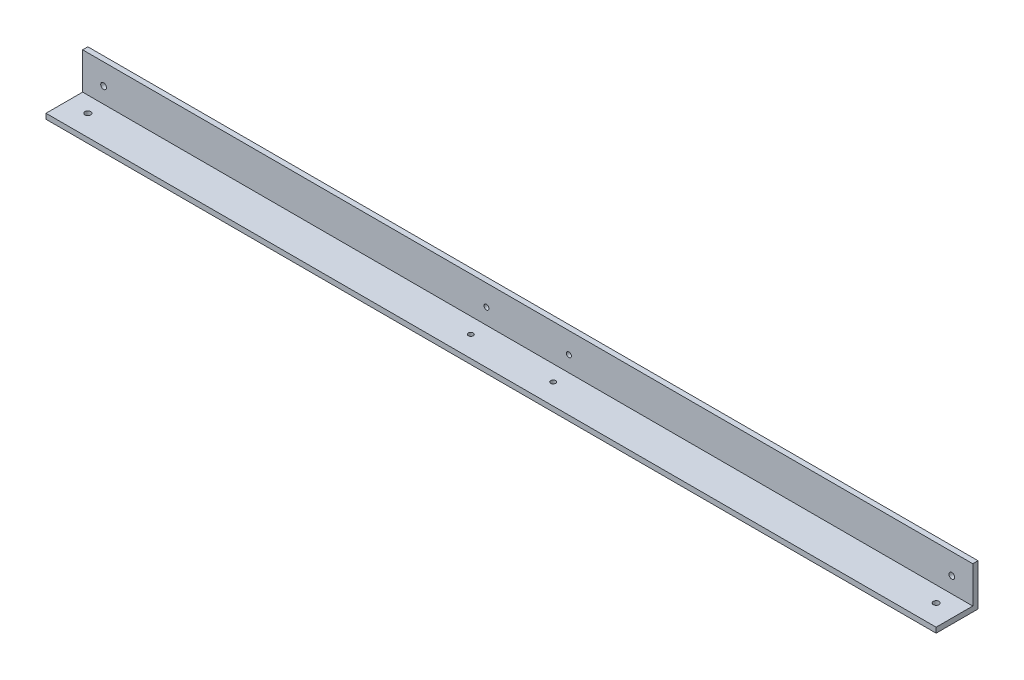
from build123d import *

# Parameters (mm, degrees)
SALIENTE_EXTRUIR1_DEPTH      = 270
SALIENTE_EXTRUIR1_DEPTH_BACK = 270
CROQUIS3_R                   = 1.5
CROQUIS3_R_2                 = 1.75
CORTAR_EXTRUIR1_DEPTH        = 3.175
CROQUIS4_R                   = 1.5
CROQUIS4_R_2                 = 1.75
CORTAR_EXTRUIR2_DEPTH        = 3.175


with BuildPart() as part:
    # Croquis1 → Saliente-Extruir1 (new body, two sides)
    with BuildSketch(Plane(origin=(0, 0, 0), x_dir=(0, 0, -1), z_dir=(1, 0, 0))) as saliente_extruir1_sk:
        Polygon((0, 25.4), (0, 0), (-25.4, 0), (-25.4, 3.175), (-3.175, 3.175), (-3.175, 25.4), align=None)
    extrude(amount=SALIENTE_EXTRUIR1_DEPTH)
    extrude(saliente_extruir1_sk.sketch, amount=-SALIENTE_EXTRUIR1_DEPTH_BACK)

    # Croquis3 → Cortar-Extruir1 (cut)
    with BuildSketch(Plane(origin=(0, 0, 0), x_dir=(-1, 0, 0), z_dir=(0, -1, 0))):
        with Locations((-25, -12.7)):
            Circle(CROQUIS3_R)
        with Locations((25, -12.7)):
            Circle(CROQUIS3_R)
        with Locations((-257.3, -12.7)):
            Circle(CROQUIS3_R_2)
        with Locations((257.3, -12.7)):
            Circle(CROQUIS3_R_2)
    extrude(amount=-CORTAR_EXTRUIR1_DEPTH, mode=Mode.SUBTRACT)

    # Croquis4 → Cortar-Extruir2 (cut)
    with BuildSketch(Plane(origin=(0, 0, 0), x_dir=(-1, 0, 0), z_dir=(0, 0, -1))):
        with Locations((25, 12.7)):
            Circle(CROQUIS4_R)
        with Locations((-25, 12.7)):
            Circle(CROQUIS4_R)
        with Locations((-257.3, 12.7)):
            Circle(CROQUIS4_R_2)
        with Locations((257.3, 12.7)):
            Circle(CROQUIS4_R_2)
    extrude(amount=-CORTAR_EXTRUIR2_DEPTH, mode=Mode.SUBTRACT)


solid = part.part
